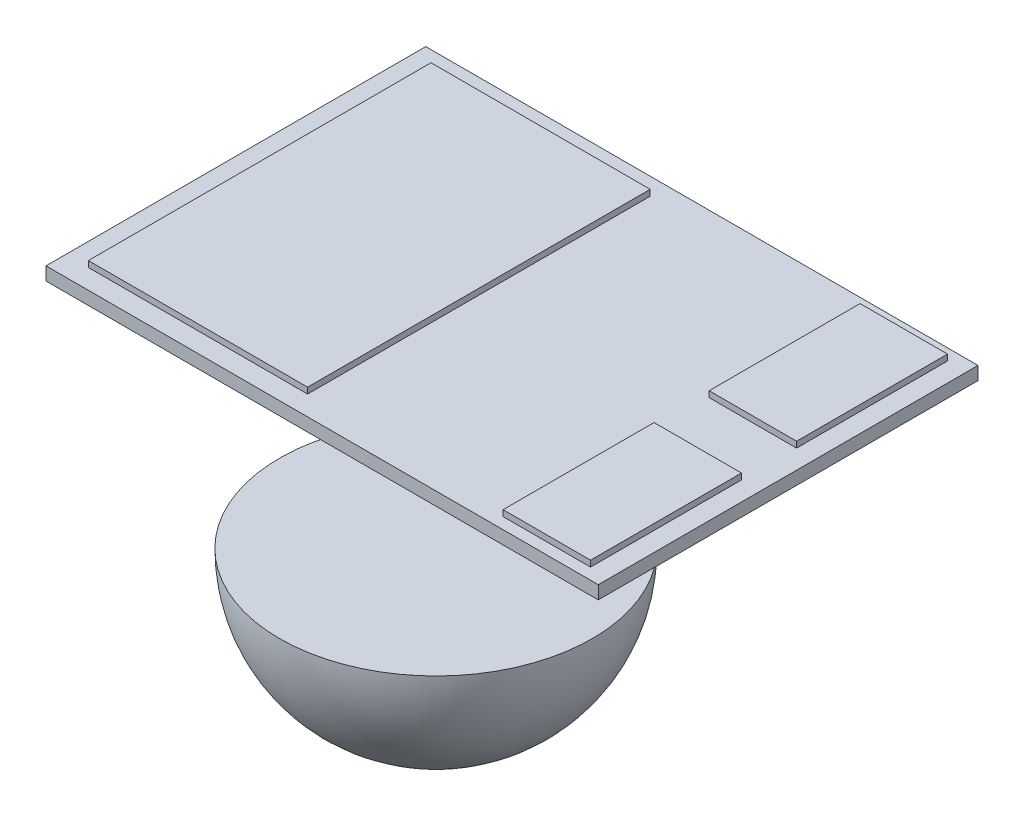
from build123d import *

# Parameters (mm, degrees)
SKETCH1_W           = 4.61
SKETCH1_H           = 3.17
BOSS_EXTRUDE1_DEPTH = 0.11
SKETCH3_W           = 1.83
SKETCH3_H           = 2.86
BOSS_EXTRUDE2_DEPTH = 0.16
SKETCH4_W           = 0.73
SKETCH4_H           = 1.26
BOSS_EXTRUDE3_DEPTH = 0.16
REVOLVE3_ANGLE      = 180


with BuildPart() as part:
    # Sketch1 → Boss-Extrude1 (new body)
    with BuildSketch(Plane(origin=(0, 0, 0), x_dir=(1, 0, 0), z_dir=(0, 1, 0))):
        with Locations((0.512582768, 0)):
            Rectangle(SKETCH1_W, SKETCH1_H)
    extrude(amount=BOSS_EXTRUDE1_DEPTH)

    # Sketch3 → Boss-Extrude2 (add)
    with BuildSketch(Plane(origin=(0, 0, 0), x_dir=(1, 0, 0), z_dir=(0, 1, 0))):
        with Locations((-0.688690494, 0.01)):
            Rectangle(SKETCH3_W, SKETCH3_H)
    extrude(amount=BOSS_EXTRUDE2_DEPTH)

    # Sketch4 → Boss-Extrude3 (add)
    with BuildSketch(Plane(origin=(0, 0, 0), x_dir=(1, 0, 0), z_dir=(0, 1, 0))):
        with Locations((2.293148726, 0.86)):
            Rectangle(SKETCH4_W, SKETCH4_H)
        with Locations((2.293148726, -0.86)):
            Rectangle(SKETCH4_W, SKETCH4_H)
    extrude(amount=BOSS_EXTRUDE3_DEPTH)


with BuildPart() as body_2:
    # Sketch6 → Revolve3 (revolve)
    with BuildSketch(Plane(origin=(0, -1.89, 0), x_dir=(-1, 0, 0), z_dir=(0, -1, 0))):
        with BuildLine():
            Line((0.122417232, 1.305), (0.122417232, -1.305))
            ThreePointArc((0.122417232, -1.305), (1.427417232, 0), (0.122417232, 1.305))
        make_face()
    revolve(axis=Axis((-0.122417232, -1.89, -1.305), (0, 0, 1)), revolution_arc=REVOLVE3_ANGLE)


solid = Compound([part.part, body_2.part])
